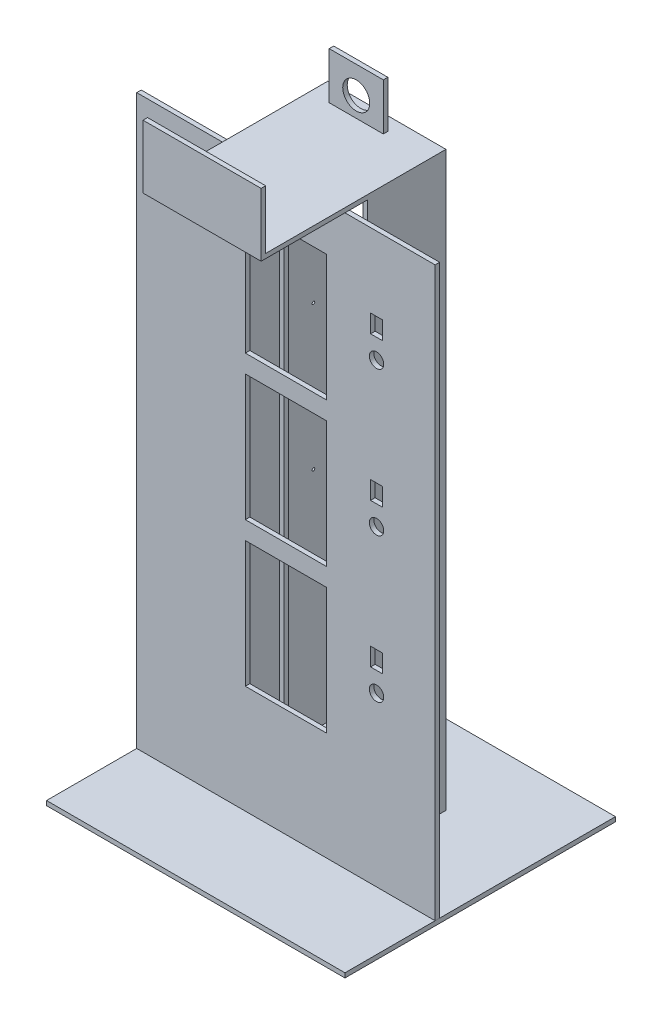
from build123d import *

# Parameters (mm, degrees)
ESQUISSE1_W             = 102
ESQUISSE1_H             = 630
BOSS_EXTRU_1_DEPTH      = 131
ESQUISSE2_W             = 121
ESQUISSE2_H             = 630
ENL_V_MAT_EXTRU_1_DEPTH = 103
ESQUISSE3_W             = 5
ESQUISSE3_H             = 630
BOSS_EXTRU_2_DEPTH      = 5
ESQUISSE4_W             = 5
ESQUISSE4_H             = 630
BOSS_EXTRU_3_DEPTH      = 5
ESQUISSE5_W             = 331
ESQUISSE5_H             = 630
BOSS_EXTRU_4_DEPTH      = 5
ESQUISSE6_W             = 90
ESQUISSE6_H             = 140
ENL_V_MAT_EXTRU_2_DEPTH = 6
ESQUISSE7_R             = 8
ESQUISSE7_W             = 13.2
ESQUISSE7_H             = 20
ENL_V_MAT_EXTRU_3_DEPTH = 108
ESQUISSE8_W             = 20
ESQUISSE8_H             = 20
ENL_V_MAT_EXTRU_4_DEPTH = 232
ESQUISSE9_W             = 131
ESQUISSE9_H             = 630
BOSS_EXTRU_5_DEPTH      = 5
ESQUISSE10_W            = 91
ESQUISSE10_H            = 540
ENL_V_MAT_EXTRU_5_DEPTH = 5
ESQUISSE11_W            = 91
ESQUISSE11_H            = 60
ENL_V_MAT_EXTRU_6_DEPTH = 5
BOSS_EXTRU_6_REACH      = 109
ESQUISSE12_W            = 20
ESQUISSE12_H            = 5
ESQUISSE13_W            = 331
ESQUISSE13_H            = 5
BOSS_EXTRU_7_DEPTH      = 100
BOSS_EXTRU_7_DEPTH_BACK = 200
ESQUISSE15_W            = 131
ESQUISSE15_H            = 5
BOSS_EXTRU_8_DEPTH      = 200
ESQUISSE16_W            = 20
ESQUISSE16_H            = 20
ENL_V_MAT_EXTRU_7_DEPTH = 232
ESQUISSE18_R            = 1.5
ENL_V_MAT_EXTRU_8_DEPTH = 106
ESQUISSE21_W            = 60
ESQUISSE21_H            = 52
ESQUISSE21_R            = 15
BOSS_EXTRU_9_DEPTH      = 5
ESQUISSE22_W            = 131
ESQUISSE22_H            = 5
BOSS_EXTRU_10_DEPTH     = 70


with BuildPart() as part:
    # Esquisse1 → Boss.-Extru.1 (new body)
    with BuildSketch(Plane(origin=(0, 0, 0), x_dir=(0, 0, -1), z_dir=(1, 0, 0))):
        with Locations((51, 315)):
            Rectangle(ESQUISSE1_W, ESQUISSE1_H)
    extrude(amount=BOSS_EXTRU_1_DEPTH)

    # Esquisse2 → Enlèv. mat.-Extru.1 (cut, through all)
    with BuildSketch(Plane.XY):
        with Locations((65.5, 315)):
            Rectangle(ESQUISSE2_W, ESQUISSE2_H)
    extrude(amount=-ENL_V_MAT_EXTRU_1_DEPTH, mode=Mode.SUBTRACT)

    # Esquisse3 → Boss.-Extru.2 (add)
    with BuildSketch(Plane(origin=(5, 0, 0), x_dir=(0, 0, -1), z_dir=(1, 0, 0))):
        with Locations((51, 315)):
            Rectangle(ESQUISSE3_W, ESQUISSE3_H)
    extrude(amount=BOSS_EXTRU_2_DEPTH)

    # Esquisse4 → Boss.-Extru.3 (add)
    with BuildSketch(Plane.ZY.offset(-126)):
        with Locations((-51, 315)):
            Rectangle(ESQUISSE4_W, ESQUISSE4_H)
    extrude(amount=BOSS_EXTRU_3_DEPTH)

    # Esquisse5 → Boss.-Extru.4 (add)
    with BuildSketch(Plane.XY):
        with Locations((65.5, 315)):
            Rectangle(ESQUISSE5_W, ESQUISSE5_H)
    extrude(amount=BOSS_EXTRU_4_DEPTH)

    # Esquisse6 → Enlèv. mat.-Extru.2 (cut, through all)
    with BuildSketch(Plane(origin=(0, 0, 0), x_dir=(-1, 0, 0), z_dir=(0, 0, -1))):
        with Locations((-65.5, 190)):
            Rectangle(ESQUISSE6_W, ESQUISSE6_H)
        with Locations((-65.5, 350)):
            Rectangle(ESQUISSE6_W, ESQUISSE6_H)
        with Locations((-65.5, 510)):
            Rectangle(ESQUISSE6_W, ESQUISSE6_H)
    extrude(amount=-ENL_V_MAT_EXTRU_2_DEPTH, mode=Mode.SUBTRACT)

    # Esquisse7 → Enlèv. mat.-Extru.3 (cut, through all)
    with BuildSketch(Plane.XY.offset(5)):
        with Locations((166, 186)):
            Circle(ESQUISSE7_R)
        with Locations((166, 346)):
            Circle(ESQUISSE7_R)
        with Locations((166, 506)):
            Circle(ESQUISSE7_R)
        with Locations((166, 218)):
            Rectangle(ESQUISSE7_W, ESQUISSE7_H)
        with Locations((166, 378)):
            Rectangle(ESQUISSE7_W, ESQUISSE7_H)
        with Locations((166, 538)):
            Rectangle(ESQUISSE7_W, ESQUISSE7_H)
    extrude(amount=-ENL_V_MAT_EXTRU_3_DEPTH, mode=Mode.SUBTRACT)

    # Esquisse8 → Enlèv. mat.-Extru.4 (cut, through all)
    with BuildSketch(Plane.ZY):
        with Locations((-10, 10)):
            Rectangle(ESQUISSE8_W, ESQUISSE8_H)
    extrude(amount=-ENL_V_MAT_EXTRU_4_DEPTH, mode=Mode.SUBTRACT)

    # Esquisse9 → Boss.-Extru.5 (add)
    with BuildSketch(Plane(origin=(0, 0, -102), x_dir=(-1, 0, 0), z_dir=(0, 0, -1))):
        with Locations((-65.5, 315)):
            Rectangle(ESQUISSE9_W, ESQUISSE9_H)
    extrude(amount=BOSS_EXTRU_5_DEPTH)

    # Esquisse10 → Enlèv. mat.-Extru.5 (cut)
    with BuildSketch(Plane(origin=(0, 0, -107), x_dir=(-1, 0, 0), z_dir=(0, 0, -1))):
        with Locations((-65.5, 345)):
            Rectangle(ESQUISSE10_W, ESQUISSE10_H)
    extrude(amount=-ENL_V_MAT_EXTRU_5_DEPTH, mode=Mode.SUBTRACT)

    # Esquisse11 → Enlèv. mat.-Extru.6 (cut)
    with BuildSketch(Plane(origin=(0, 0, -107), x_dir=(-1, 0, 0), z_dir=(0, 0, -1))):
        with Locations((-65.5, 30)):
            Rectangle(ESQUISSE11_W, ESQUISSE11_H)
    extrude(amount=-ENL_V_MAT_EXTRU_6_DEPTH, mode=Mode.SUBTRACT)

    # Esquisse12 → Boss.-Extru.6 (add, up to next)
    with BuildSketch(Plane.XY.offset(-102), mode=Mode.PRIVATE) as boss_extru_6_sk1:
        with Locations((65.5, 72.5)):
            Rectangle(ESQUISSE12_W, ESQUISSE12_H)
    boss_extru_6_tool1 = extrude(boss_extru_6_sk1.sketch, amount=BOSS_EXTRU_6_REACH, mode=Mode.PRIVATE) - part.part
    add(boss_extru_6_tool1.solids().sort_by_distance((65.5, 72.5, -102))[0])

    # Esquisse15 → Boss.-Extru.8 (add)
    with BuildSketch(Plane(origin=(0, 0, -107), x_dir=(-1, 0, 0), z_dir=(0, 0, -1))):
        with Locations((-65.5, 632.5)):
            Rectangle(ESQUISSE15_W, ESQUISSE15_H)
    extrude(amount=-BOSS_EXTRU_8_DEPTH)

    # Esquisse16 → Enlèv. mat.-Extru.7 (cut, through all)
    with BuildSketch(Plane(origin=(131, 0, 0), x_dir=(0, 0, -1), z_dir=(1, 0, 0))):
        with Locations((10, 620)):
            Rectangle(ESQUISSE16_W, ESQUISSE16_H)
    extrude(amount=-ENL_V_MAT_EXTRU_7_DEPTH, mode=Mode.SUBTRACT)

    # Esquisse18 → Enlèv. mat.-Extru.8 (cut, through all)
    with BuildSketch(Plane(origin=(5, 0, 0), x_dir=(0, 0, -1), z_dir=(1, 0, 0))):
        with Locations((86, 595)):
            Circle(ESQUISSE18_R)
        with Locations((86, 435)):
            Circle(ESQUISSE18_R)
        with Locations((86, 275)):
            Circle(ESQUISSE18_R)
    extrude(amount=-ENL_V_MAT_EXTRU_8_DEPTH, mode=Mode.SUBTRACT)

    # Esquisse21 → Boss.-Extru.9 (add)
    with BuildSketch(Plane(origin=(0, 0, -87), x_dir=(-1, 0, 0), z_dir=(0, 0, -1))):
        with Locations((-51.5, 661)):
            Rectangle(ESQUISSE21_W, ESQUISSE21_H)
        with Locations((-51.5, 657)):
            Circle(ESQUISSE21_R, mode=Mode.SUBTRACT)
    extrude(amount=BOSS_EXTRU_9_DEPTH)

    # Esquisse22 → Boss.-Extru.10 (add)
    with BuildSketch(Plane.XZ.offset(-630)):
        with Locations((65.5, 95.5)):
            Rectangle(ESQUISSE22_W, ESQUISSE22_H)
    extrude(amount=-BOSS_EXTRU_10_DEPTH)


with BuildPart() as body_2:
    # Esquisse13 → Boss.-Extru.7 (new body, two sides)
    with BuildSketch(Plane.XY.offset(5)) as boss_extru_7_sk:
        with Locations((65.5, -2.5)):
            Rectangle(ESQUISSE13_W, ESQUISSE13_H)
    extrude(amount=BOSS_EXTRU_7_DEPTH)
    extrude(boss_extru_7_sk.sketch, amount=-BOSS_EXTRU_7_DEPTH_BACK)


solid = Compound([part.part, body_2.part])
